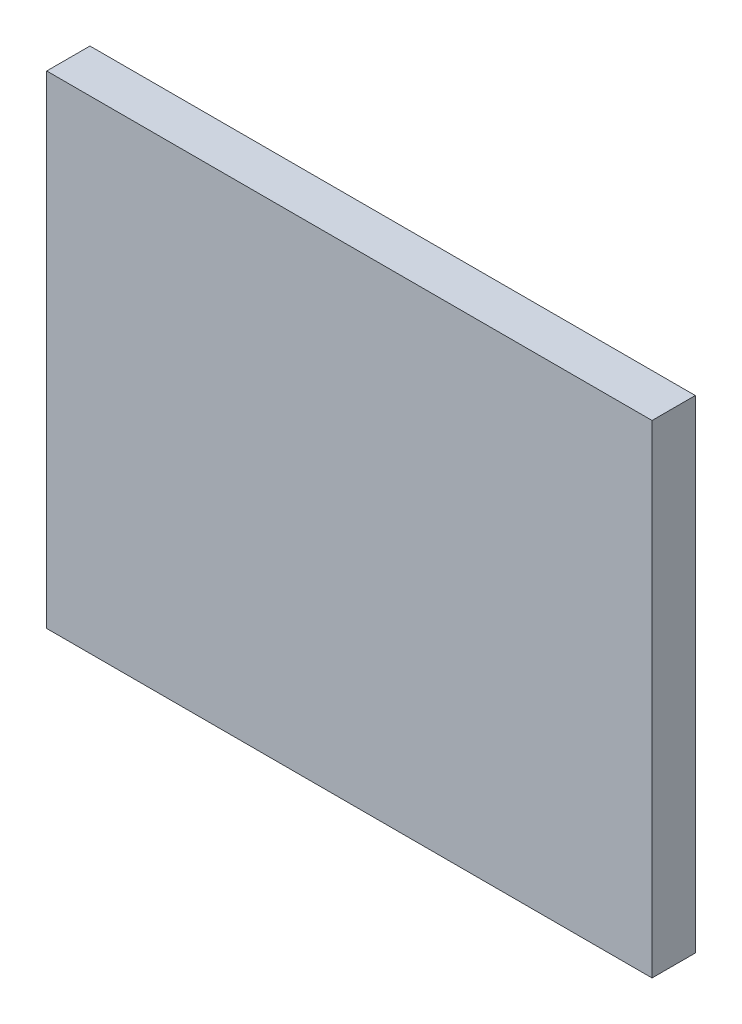
from build123d import *

# Parameters (mm, degrees)
SKETCH1_W           = 42
SKETCH1_H           = 33.5
BOSS_EXTRUDE1_DEPTH = 3


with BuildPart() as part:
    # Sketch1 → Boss-Extrude1 (new body)
    with BuildSketch(Plane.XY):
        Rectangle(SKETCH1_W, SKETCH1_H)
    extrude(amount=BOSS_EXTRUDE1_DEPTH)


solid = part.part
